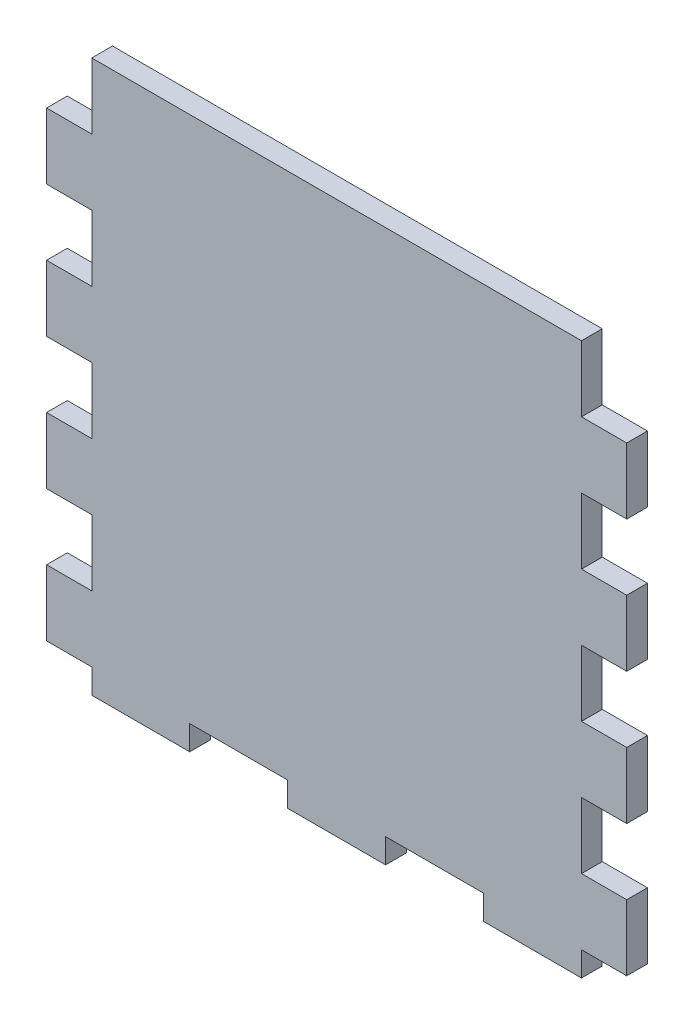
from build123d import *

# Parameters (mm, degrees)
SKETCH1_W           = 65
SKETCH1_H           = 70
BOSS_EXTRUDE1_DEPTH = 2.75
SKETCH2_W           = 6
SKETCH2_H           = 8.75
SKETCH2_W_2         = 13
SKETCH2_H_2         = 3.25
BOSS_EXTRUDE2_DEPTH = 2.75


with BuildPart() as part:
    # Sketch1 → Boss-Extrude1 (new body)
    with BuildSketch(Plane.XY):
        with Locations((32.5, 35)):
            Rectangle(SKETCH1_W, SKETCH1_H)
    extrude(amount=BOSS_EXTRUDE1_DEPTH)

    # Sketch2 → Boss-Extrude2 (add)
    with BuildSketch(Plane.XY.offset(2.75)):
        with Locations((68, 39.375)):
            Rectangle(SKETCH2_W, SKETCH2_H)
        with Locations((68, 21.875)):
            Rectangle(SKETCH2_W, SKETCH2_H)
        with Locations((68, 4.375)):
            Rectangle(SKETCH2_W, SKETCH2_H)
        with Locations((6.5, -1.625)):
            Rectangle(SKETCH2_W_2, SKETCH2_H_2)
        with Locations((-3, 4.375)):
            Rectangle(SKETCH2_W, SKETCH2_H)
        with Locations((-3, 21.875)):
            Rectangle(SKETCH2_W, SKETCH2_H)
        with Locations((-3, 56.875)):
            Rectangle(SKETCH2_W, SKETCH2_H)
        with Locations((68, 56.875)):
            Rectangle(SKETCH2_W, SKETCH2_H)
        with Locations((58.5, -1.625)):
            Rectangle(SKETCH2_W_2, SKETCH2_H_2)
        with Locations((32.5, -1.625)):
            Rectangle(SKETCH2_W_2, SKETCH2_H_2)
        with Locations((-3, 39.375)):
            Rectangle(SKETCH2_W, SKETCH2_H)
    extrude(amount=-BOSS_EXTRUDE2_DEPTH)


solid = part.part
